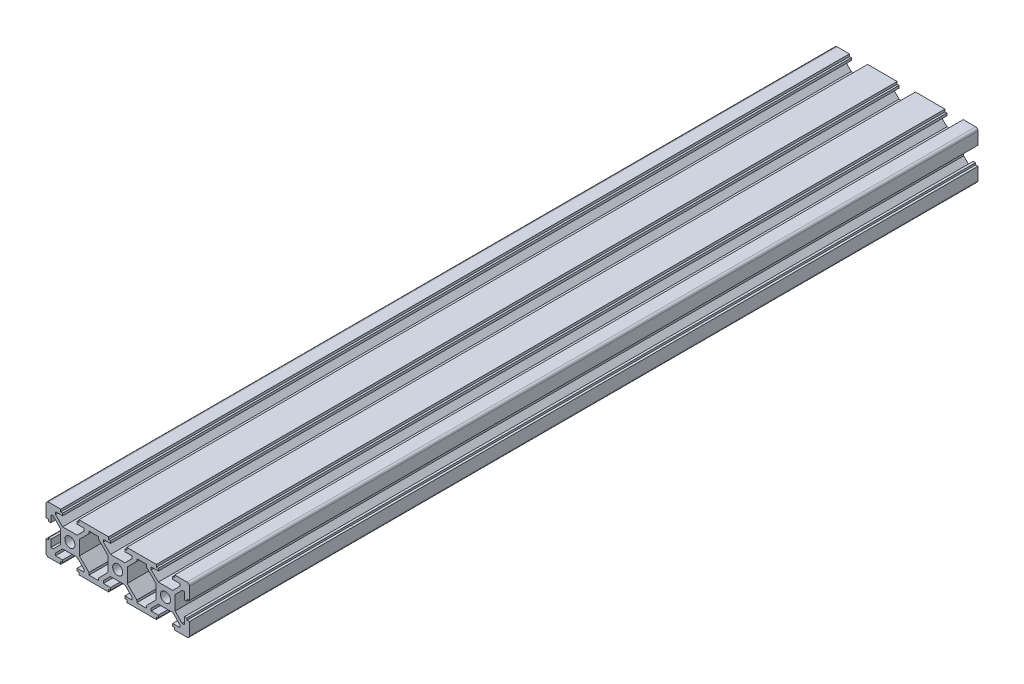
from build123d import *

# Parameters (mm, degrees)
SKETCH_1_R      = 2.103037388
EXTRUDE_1_DEPTH = 330


with BuildPart() as part:
    # 草图1 → 凸台-拉伸1 (new body)
    with BuildSketch(Plane.XY):
        with BuildLine():
            Line((-32.248557314, -0.229845073), (-32.248557314, -1.030984477))
            Line((-32.248557314, -1.030984477), (-33.250003689, -1.030984477))
            Line((-33.250003689, -1.030984477), (-33.250003689, -6.238394755))
            ThreePointArc((-33.250003689, -6.238394755), (-32.949991565, -6.938952391), (-32.24382973, -7.225524788))
            Line((-32.24382973, -7.225524788), (-27.078556151, -7.225524788))
            Line((-27.078556151, -7.225524788), (-27.078556151, -6.224078413))
            Line((-27.078556151, -6.224078413), (-26.277399051, -6.224078413))
            Line((-26.277399051, -6.224078413), (-26.277399051, -5.212715786))
            Line((-26.277399051, -5.212715786), (-29.27300496, -5.212715786))
            Line((-29.27300496, -5.212715786), (-29.27300496, -4.211495229))
            Line((-29.27300496, -4.211495229), (-26.279632969, -1.225390538))
            Line((-26.279632969, -1.225390538), (-20.24902045, -1.225390538))
            Line((-20.24902045, -1.225390538), (-17.255648459, -4.211495229))
            Line((-17.255648459, -4.211495229), (-17.255648459, -5.212715786))
            Line((-17.255648459, -5.212715786), (-20.251254368, -5.212715786))
            Line((-20.251254368, -5.212715786), (-20.251254368, -6.224078413))
            Line((-20.251254368, -6.224078413), (-19.450097268, -6.224078413))
            Line((-19.450097268, -6.224078413), (-19.450097268, -7.225524788))
            Line((-19.450097268, -7.225524788), (-7.064233131, -7.225524788))
            Line((-7.064233131, -7.225524788), (-7.064233131, -6.224078413))
            Line((-7.064233131, -6.224078413), (-6.263076031, -6.224078413))
            Line((-6.263076031, -6.224078413), (-6.263076031, -5.212715786))
            Line((-6.263076031, -5.212715786), (-9.25868194, -5.212715786))
            Line((-9.25868194, -5.212715786), (-9.25868194, -4.211495229))
            Line((-9.25868194, -4.211495229), (-6.265309949, -1.225390538))
            Line((-6.265309949, -1.225390538), (-0.234697429, -1.225390538))
            Line((-0.234697429, -1.225390538), (2.758674561, -4.211495229))
            Line((2.758674561, -4.211495229), (2.758674561, -5.212715786))
            Line((2.758674561, -5.212715786), (-0.236931348, -5.212715786))
            Line((-0.236931348, -5.212715786), (-0.236931348, -6.224078413))
            Line((-0.236931348, -6.224078413), (0.564225752, -6.224078413))
            Line((0.564225752, -6.224078413), (0.564225752, -7.225524788))
            Line((0.564225752, -7.225524788), (12.945482254, -7.225524788))
            Line((12.945482254, -7.225524788), (12.945482254, -6.219120287))
            Line((12.945482254, -6.219120287), (13.751246989, -6.219120287))
            Line((13.751246989, -6.219120287), (13.751246989, -5.212715786))
            Line((13.751246989, -5.212715786), (10.755641081, -5.212715786))
            Line((10.755641081, -5.212715786), (10.755641081, -4.211495229))
            Line((10.755641081, -4.211495229), (13.749013071, -1.225390538))
            Line((13.749013071, -1.225390538), (19.779625591, -1.225390538))
            Line((19.779625591, -1.225390538), (22.772997581, -4.211495229))
            Line((22.772997581, -4.211495229), (22.772997581, -5.212715786))
            Line((22.772997581, -5.212715786), (19.772784037, -5.212715786))
            Line((19.772784037, -5.212715786), (19.772784037, -6.219120287))
            Line((19.772784037, -6.219120287), (20.573941137, -6.219120287))
            Line((20.573941137, -6.219120287), (20.573941137, -7.225524788))
            Line((20.573941137, -7.225524788), (25.743822351, -7.225524788))
            ThreePointArc((25.743822351, -7.225524788), (26.449984187, -6.938952391), (26.749996311, -6.238394755))
            Line((26.749996311, -6.238394755), (26.749996311, -1.030984477))
            Line((26.749996311, -1.030984477), (25.748549936, -1.030984477))
            Line((25.748549936, -1.030984477), (25.748549936, -0.229827377))
            Line((25.748549936, -0.229827377), (24.761302481, -0.229827377))
            Line((24.761302481, -0.229827377), (24.761302481, -3.234203038))
            Line((24.761302481, -3.234203038), (23.759856106, -3.234203038))
            Line((23.759856106, -3.234203038), (20.770104831, -0.237175589))
            Line((20.770104831, -0.237175589), (20.770104831, 5.786126014))
            Line((20.770104831, 5.786126014), (23.759856106, 8.783153462))
            Line((23.759856106, 8.783153462), (24.761302481, 8.783153462))
            Line((24.761302481, 8.783153462), (24.761302481, 5.778777801))
            Line((24.761302481, 5.778777801), (25.748549936, 5.778777801))
            Line((25.748549936, 5.778777801), (25.748549936, 6.579934901))
            Line((25.748549936, 6.579934901), (26.749996311, 6.579934901))
            Line((26.749996311, 6.579934901), (26.749996311, 11.768212512))
            ThreePointArc((26.749996311, 11.768212512), (26.456722319, 12.481138347), (25.743822351, 12.774475212))
            Line((25.743822351, 12.774475212), (20.573941137, 12.774475212))
            Line((20.573941137, 12.774475212), (20.573941137, 11.768070711))
            Line((20.573941137, 11.768070711), (19.772784037, 11.768070711))
            Line((19.772784037, 11.768070711), (19.772784037, 10.761666211))
            Line((19.772784037, 10.761666211), (22.772997581, 10.761666211))
            Line((22.772997581, 10.761666211), (22.772997581, 9.760445653))
            Line((22.772997581, 9.760445653), (19.779625591, 6.774340962))
            Line((19.779625591, 6.774340962), (13.749013071, 6.774340962))
            Line((13.749013071, 6.774340962), (10.755641081, 9.760445653))
            Line((10.755641081, 9.760445653), (10.755641081, 10.761666211))
            Line((10.755641081, 10.761666211), (13.746639354, 10.761666211))
            Line((13.746639354, 10.761666211), (13.746639354, 11.768070711))
            Line((13.746639354, 11.768070711), (12.945482254, 11.768070711))
            Line((12.945482254, 11.768070711), (12.945482254, 12.774475212))
            Line((12.945482254, 12.774475212), (0.564225752, 12.774475212))
            Line((0.564225752, 12.774475212), (0.564225752, 11.773028837))
            Line((0.564225752, 11.773028837), (-0.236931348, 11.773028837))
            Line((-0.236931348, 11.773028837), (-0.236931348, 10.761666211))
            Line((-0.236931348, 10.761666211), (2.758674561, 10.761666211))
            Line((2.758674561, 10.761666211), (2.758674561, 9.760445653))
            Line((2.758674561, 9.760445653), (-0.234697429, 6.774340962))
            Line((-0.234697429, 6.774340962), (-6.265309949, 6.774340962))
            Line((-6.265309949, 6.774340962), (-9.25868194, 9.760445653))
            Line((-9.25868194, 9.760445653), (-9.25868194, 10.761666211))
            Line((-9.25868194, 10.761666211), (-6.263076031, 10.761666211))
            Line((-6.263076031, 10.761666211), (-6.263076031, 11.773028837))
            Line((-6.263076031, 11.773028837), (-7.064233131, 11.773028837))
            Line((-7.064233131, 11.773028837), (-7.064233131, 12.774475212))
            Line((-7.064233131, 12.774475212), (-19.450097268, 12.774475212))
            Line((-19.450097268, 12.774475212), (-19.450097268, 11.773028837))
            Line((-19.450097268, 11.773028837), (-20.251254368, 11.773028837))
            Line((-20.251254368, 11.773028837), (-20.251254368, 10.761666211))
            Line((-20.251254368, 10.761666211), (-17.255648459, 10.761666211))
            Line((-17.255648459, 10.761666211), (-17.255648459, 9.760445653))
            Line((-17.255648459, 9.760445653), (-20.24902045, 6.774340962))
            Line((-20.24902045, 6.774340962), (-26.279632969, 6.774340962))
            Line((-26.279632969, 6.774340962), (-29.27300496, 9.760445653))
            Line((-29.27300496, 9.760445653), (-29.27300496, 10.761666211))
            Line((-29.27300496, 10.761666211), (-26.277399051, 10.761666211))
            Line((-26.277399051, 10.761666211), (-26.277399051, 11.773028837))
            Line((-26.277399051, 11.773028837), (-27.078556151, 11.773028837))
            Line((-27.078556151, 11.773028837), (-27.078556151, 12.774475212))
            Line((-27.078556151, 12.774475212), (-32.24382973, 12.774475212))
            ThreePointArc((-32.24382973, 12.774475212), (-32.956729698, 12.481138347), (-33.250003689, 11.768212512))
            Line((-33.250003689, 11.768212512), (-33.250003689, 6.560802234))
            Line((-33.250003689, 6.560802234), (-32.248557314, 6.560802234))
            Line((-32.248557314, 6.560802234), (-32.248557314, 5.759645134))
            Line((-32.248557314, 5.759645134), (-31.261309859, 5.759645134))
            Line((-31.261309859, 5.759645134), (-31.261309859, 8.764020795))
            Line((-31.261309859, 8.764020795), (-30.259863484, 8.764020795))
            Line((-30.259863484, 8.764020795), (-27.27011221, 5.766993347))
            Line((-27.27011221, 5.766993347), (-27.27011221, -0.237175589))
            Line((-27.27011221, -0.237175589), (-30.259863484, -3.234203038))
            Line((-30.259863484, -3.234203038), (-31.261309859, -3.234203038))
            Line((-31.261309859, -3.234203038), (-31.261309859, -0.229845073))
            Line((-31.261309859, -0.229845073), (-32.248557314, -0.229845073))
        make_face()
        with Locations((-3.250003689, 2.774475212)):
            Circle(SKETCH_1_R, mode=Mode.SUBTRACT)
        with Locations((-23.250003689, 2.774475212)):
            Circle(SKETCH_1_R, mode=Mode.SUBTRACT)
        with Locations((16.749996311, 2.774475212)):
            Circle(SKETCH_1_R, mode=Mode.SUBTRACT)
        Polygon((-19.258541209, 5.786126014), (-19.258541209, -0.237175589), (-15.26734356, -4.238086639), (-15.26734356, -5.22228212), (-11.246986839, -5.22228212), (-11.246986839, -4.238086639), (-7.25578919, -0.237175589), (-7.25578919, 2.774475212), (-7.25578919, 5.786126014), (-11.246986839, 9.787037063), (-11.246986839, 10.771232544), (-15.26734356, 10.771232544), (-15.26734356, 9.787037063), align=None, mode=Mode.SUBTRACT)
        Polygon((4.74697946, -5.22228212), (8.767336181, -5.22228212), (8.767336181, -4.238086639), (12.758533831, -0.237175589), (12.758533831, 2.774475212), (12.758533831, 5.786126014), (8.767336181, 9.787037063), (8.767336181, 10.771232544), (4.74697946, 10.771232544), (4.74697946, 9.787037063), (0.755781811, 5.786126014), (0.755781811, 2.774475212), (0.755781811, -0.237175589), (4.74697946, -4.238086639), align=None, mode=Mode.SUBTRACT)
    extrude(amount=EXTRUDE_1_DEPTH)


solid = part.part
